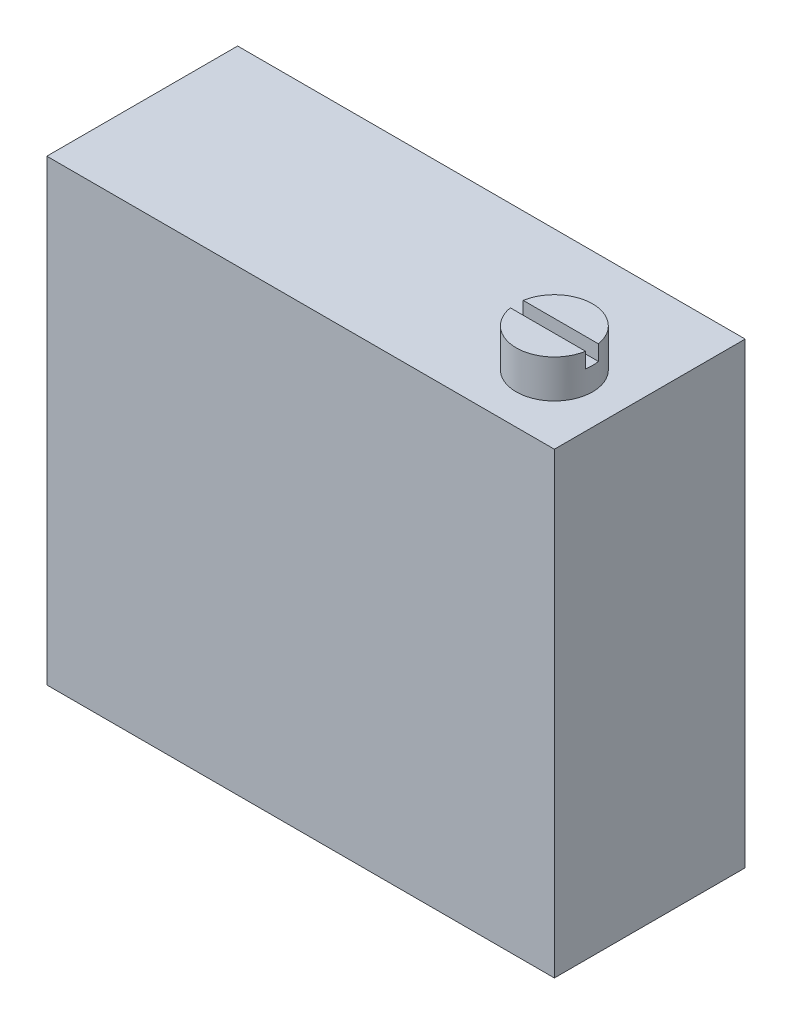
from build123d import *

# Parameters (mm, degrees)
SKETCH_1_W          = 13.3
SKETCH_1_H          = 5
EXTRUDE_1_DEPTH     = 12
SKETCH_2_R          = 1
EXTRUDE_2_DEPTH     = 1
SKETCH_3_W          = 2.738665781
SKETCH_3_H          = 0.337471602
CUT_EXTRUDE_1_DEPTH = 0.4


with BuildPart() as part:
    # Эскиз1 → Бобышка-Вытянуть1 (new body)
    with BuildSketch(Plane(origin=(0, 0, 0), x_dir=(1, 0, 0), z_dir=(0, 1, 0))):
        with Locations((-38.349307958, -18.52646235)):
            Rectangle(SKETCH_1_W, SKETCH_1_H)
    extrude(amount=EXTRUDE_1_DEPTH)

    # Эскиз2 → Бобышка-Вытянуть2 (add)
    with BuildSketch(Plane(origin=(0, 12, 0), x_dir=(1, 0, 0), z_dir=(0, 1, 0))):
        with Locations((-33.499307958, -19.22646235)):
            Circle(SKETCH_2_R)
    extrude(amount=EXTRUDE_2_DEPTH)

    # Эскиз3 → Вырез-Вытянуть1 (cut)
    with BuildSketch(Plane(origin=(0, 13, 0), x_dir=(1, 0, 0), z_dir=(0, 1, 0))):
        with Locations((-33.499307958, -19.22646235)):
            Rectangle(SKETCH_3_W, SKETCH_3_H)
    extrude(amount=-CUT_EXTRUDE_1_DEPTH, mode=Mode.SUBTRACT)


solid = part.part
